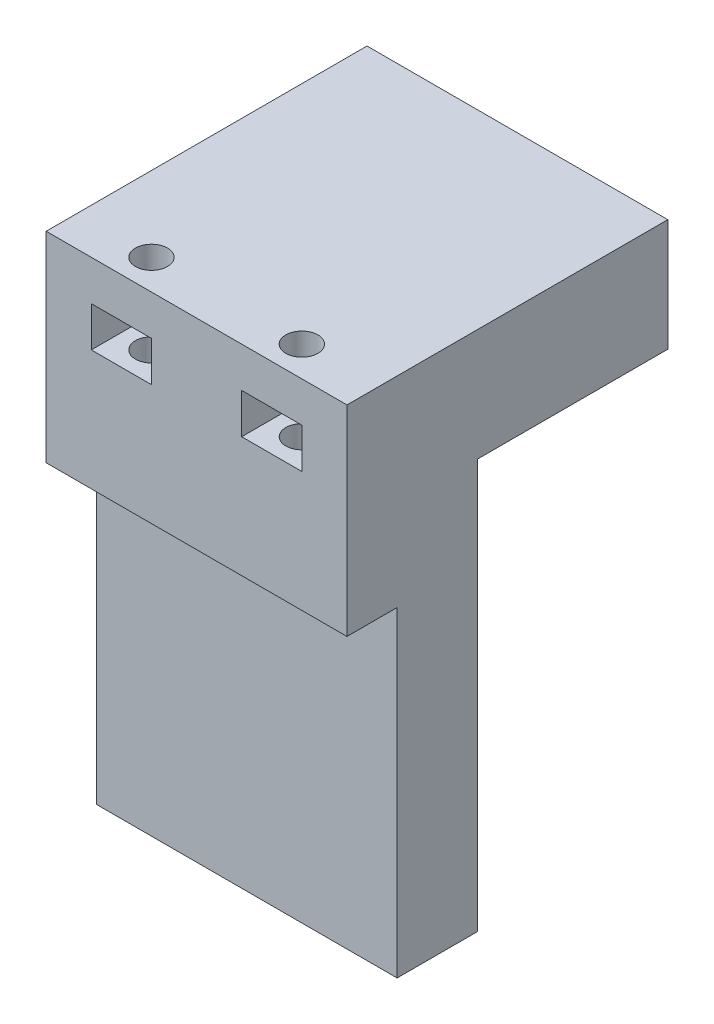
from build123d import *

# Parameters (mm, degrees)
SKETCH_2_W          = 30
SKETCH_2_H          = 52
EXTRUDE_1_DEPTH     = 5
SKETCH_3_W          = 5
SKETCH_3_H          = 40.81
EXTRUDE_2_DEPTH     = 3
SKETCH_4_W          = 30
SKETCH_4_H          = 10
EXTRUDE_3_DEPTH     = 20
SKETCH_6_R          = 1.6
CUT_EXTRUDE_1_DEPTH = 15
SKETCH_7_W          = 6
SKETCH_7_H          = 4
CUT_EXTRUDE_2_DEPTH = 6
SKETCH_8_W          = 30
SKETCH_8_H          = 11.19
EXTRUDE_4_DEPTH     = 22
SKETCH_9_R          = 2.5
CUT_EXTRUDE_3_DEPTH = 10
SKETCH_10_W         = 6
SKETCH_10_H         = 3.5
CUT_EXTRUDE_4_DEPTH = 8


with BuildPart() as part:
    # 草图2 → 凸台-拉伸1 (new body)
    with BuildSketch(Plane.XY):
        with Locations((0, -11.302890995)):
            Rectangle(SKETCH_2_W, SKETCH_2_H)
    extrude(amount=EXTRUDE_1_DEPTH)

    # 草图3 → 凸台-拉伸2 (add)
    with BuildSketch(Plane.XY):
        with Locations((-12.5, -16.897890995)):
            Rectangle(SKETCH_3_W, SKETCH_3_H)
        with Locations((12.5, -16.897890995)):
            Rectangle(SKETCH_3_W, SKETCH_3_H)
    extrude(amount=-EXTRUDE_2_DEPTH)

    # 草图4 → 凸台-拉伸3 (add)
    with BuildSketch(Plane(origin=(0, 14.697109005, 0), x_dir=(1, 0, 0), z_dir=(0, 1, 0))):
        with Locations((0, -5)):
            Rectangle(SKETCH_4_W, SKETCH_4_H)
    extrude(amount=-EXTRUDE_3_DEPTH)

    # 草图6 → 切除-拉伸1 (cut)
    with BuildSketch(Plane(origin=(0, 14.697109005, 0), x_dir=(1, 0, 0), z_dir=(0, 1, 0))):
        with Locations((-7.5, -7)):
            Circle(SKETCH_6_R)
        with Locations((7.5, -7)):
            Circle(SKETCH_6_R)
    extrude(amount=-CUT_EXTRUDE_1_DEPTH, mode=Mode.SUBTRACT)

    # 草图7 → 切除-拉伸2 (cut)
    with BuildSketch(Plane.XY.offset(10)):
        with Locations((-7.5, 8.697109005)):
            Rectangle(SKETCH_7_W, SKETCH_7_H)
        with Locations((7.5, 8.697109005)):
            Rectangle(SKETCH_7_W, SKETCH_7_H)
    extrude(amount=-CUT_EXTRUDE_2_DEPTH, mode=Mode.SUBTRACT)

    # 草图8 → 凸台-拉伸4 (add)
    with BuildSketch(Plane.XY):
        with Locations((0, 9.102109005)):
            Rectangle(SKETCH_8_W, SKETCH_8_H)
    extrude(amount=-EXTRUDE_4_DEPTH)

    # 草图9 → 切除-拉伸3 (cut)
    with BuildSketch(Plane(origin=(0, 0, -22), x_dir=(-1, 0, 0), z_dir=(0, 0, -1))):
        with Locations((-5, 7.507109005)):
            Circle(SKETCH_9_R)
        with Locations((5, 7.507109005)):
            Circle(SKETCH_9_R)
    extrude(amount=-CUT_EXTRUDE_3_DEPTH, mode=Mode.SUBTRACT)

    # 草图10 → 切除-拉伸4 (cut)
    with BuildSketch(Plane(origin=(0, 3.507109005, 0), x_dir=(-1, 0, 0), z_dir=(0, -1, 0))):
        with Locations((5, 17)):
            Rectangle(SKETCH_10_W, SKETCH_10_H)
        with Locations((-5, 17)):
            Rectangle(SKETCH_10_W, SKETCH_10_H)
    extrude(amount=-CUT_EXTRUDE_4_DEPTH, mode=Mode.SUBTRACT)


solid = part.part
